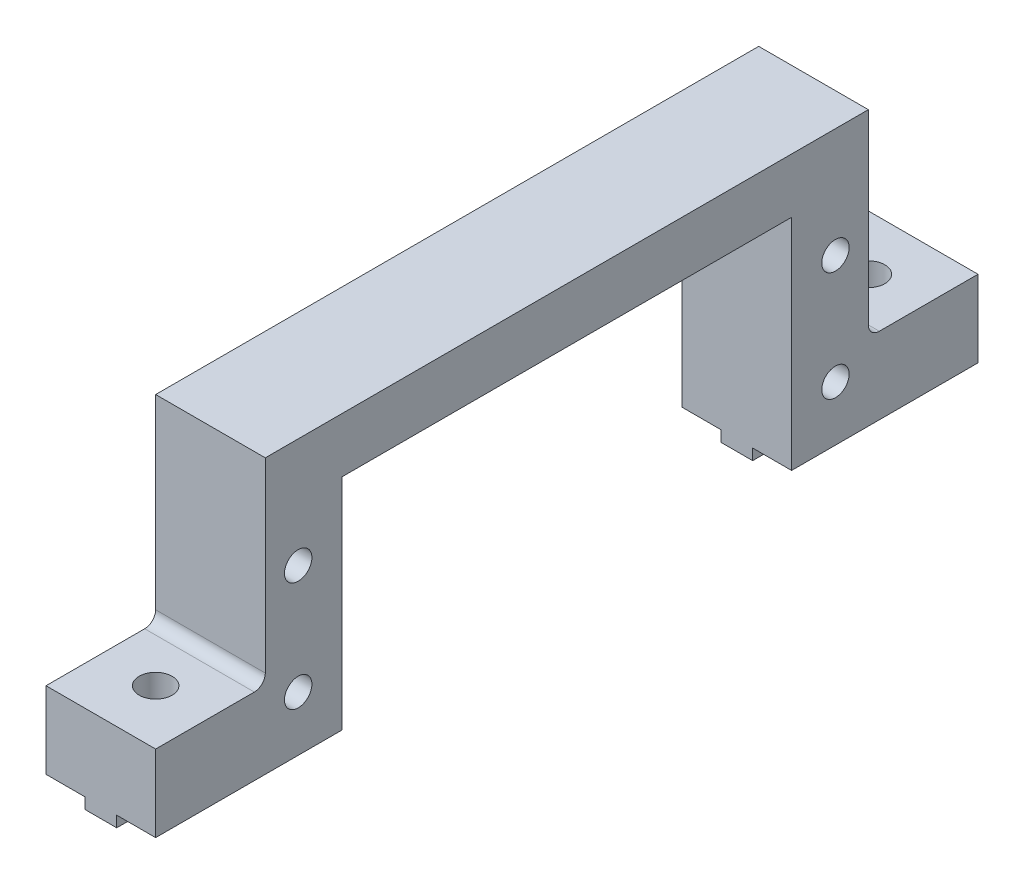
from build123d import *

# Parameters (mm, degrees)
MAIN_DEPTH                   = 37.5
SKETCH2_W                    = 41
SKETCH2_H                    = 21
SERVOPLACE_DEPTH             = 11
SKETCH3_R                    = 1.25
SERVOFIXHOLE_DEPTH           = 11
SKETCH4_W                    = 10
SKETCH4_H                    = 10
CUTFORFIXMAKERBEAMHOLE_DEPTH = 18
SKETCH5_R                    = 1.5
FIXHOLEMAKERBEAM_DEPTH       = 9
FILLET1_R                    = 1


with BuildPart() as part:
    # Sketch1 → Main (new body, symmetric)
    with BuildSketch(Plane.XY):
        Polygon((-5, 0), (-5, 25), (5, 25), (5, 0), (1.45, 0), (1.45, -1), (-1.45, -1), (-1.45, 0), align=None)
    extrude(amount=MAIN_DEPTH, both=True)

    # Sketch2 → ServoPlace (cut, through all)
    with BuildSketch(Plane.ZY.offset(5)):
        with Locations((0, 9.5)):
            Rectangle(SKETCH2_W, SKETCH2_H)
    extrude(amount=-SERVOPLACE_DEPTH, mode=Mode.SUBTRACT)

    # Sketch3 → ServoFixHole (cut, through all)
    with BuildSketch(Plane.ZY.offset(5)):
        with Locations((-24.5, 15)):
            Circle(SKETCH3_R)
        with Locations((-24.5, 5)):
            Circle(SKETCH3_R)
    servofixhole = extrude(amount=-SERVOFIXHOLE_DEPTH, mode=Mode.SUBTRACT)

    # ServoFixHoleMirror: ServoFixHole across plane
    add(servofixhole.mirror(Plane.XY), mode=Mode.SUBTRACT)

    # Sketch4 → CutForFixMakerBeamHole (cut)
    with BuildSketch(Plane(origin=(0, 25, 0), x_dir=(1, 0, 0), z_dir=(0, 1, 0))):
        with Locations((0, 32.5)):
            Rectangle(SKETCH4_W, SKETCH4_H)
        with Locations((0, -32.5)):
            Rectangle(SKETCH4_W, SKETCH4_H)
    extrude(amount=-CUTFORFIXMAKERBEAMHOLE_DEPTH, mode=Mode.SUBTRACT)

    # Sketch5 → FixHoleMakerBeam (cut, through all)
    with BuildSketch(Plane(origin=(0, 7, 0), x_dir=(1, 0, 0), z_dir=(0, 1, 0))):
        with Locations((0, 32.5)):
            Circle(SKETCH5_R)
        with Locations((0, -32.5)):
            Circle(SKETCH5_R)
    extrude(amount=-FIXHOLEMAKERBEAM_DEPTH, mode=Mode.SUBTRACT)

    # Fillet1
    fillet1_edges = [part.edges().sort_by_distance(p)[0] for p in [
        (0, 7, -27.5),
        (0, 7, 27.5),
    ]]
    fillet(fillet1_edges, radius=FILLET1_R)


solid = part.part
